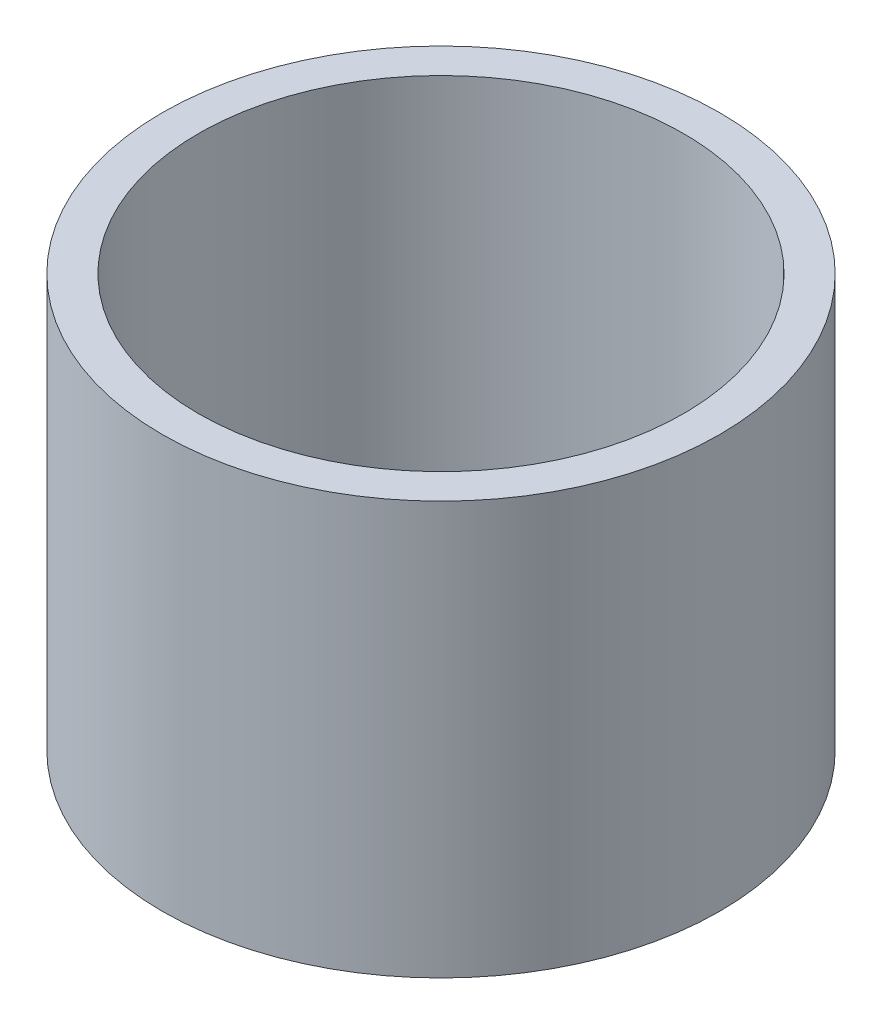
from build123d import *

# Parameters (mm, degrees)
SKETCH1_R           = 27
SKETCH1_R_2         = 23.5
BOSS_EXTRUDE1_DEPTH = 40


with BuildPart() as part:
    # Sketch1 → Boss-Extrude1 (new body)
    with BuildSketch(Plane(origin=(0, 0, 0), x_dir=(1, 0, 0), z_dir=(0, 1, 0))):
        Circle(SKETCH1_R)
        Circle(SKETCH1_R_2, mode=Mode.SUBTRACT)
    extrude(amount=BOSS_EXTRUDE1_DEPTH)


solid = part.part
